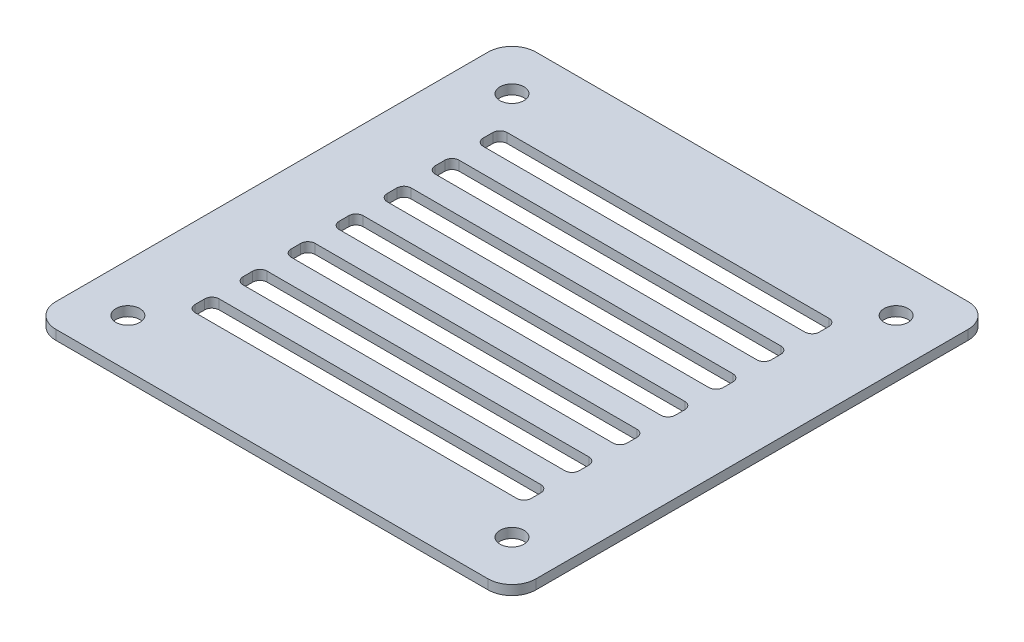
from build123d import *

# Parameters (mm, degrees)
SKETCH1_W           = 100
SKETCH1_H           = 100
SKETCH1_R           = 2.5
SKETCH1_W_2         = 70
SKETCH1_H_2         = 5
BOSS_EXTRUDE1_DEPTH = 2
FILLET1_R           = 5
FILLET2_R           = 1.5


with BuildPart() as part:
    # Sketch1 → Boss-Extrude1 (new body)
    with BuildSketch(Plane(origin=(0, 0, 0), x_dir=(1, 0, 0), z_dir=(0, 1, 0))):
        Rectangle(SKETCH1_W, SKETCH1_H)
        with Locations((-40, 40)):
            Circle(SKETCH1_R, mode=Mode.SUBTRACT)
        with Locations((40, 40)):
            Circle(SKETCH1_R, mode=Mode.SUBTRACT)
        with Locations((40, -40)):
            Circle(SKETCH1_R, mode=Mode.SUBTRACT)
        with Locations((-40, -40)):
            Circle(SKETCH1_R, mode=Mode.SUBTRACT)
        with Locations((0, -30)):
            Rectangle(SKETCH1_W_2, SKETCH1_H_2, mode=Mode.SUBTRACT)
        with Locations((0, -20)):
            Rectangle(SKETCH1_W_2, SKETCH1_H_2, mode=Mode.SUBTRACT)
        with Locations((0, -10)):
            Rectangle(SKETCH1_W_2, SKETCH1_H_2, mode=Mode.SUBTRACT)
        Rectangle(SKETCH1_W_2, SKETCH1_H_2, mode=Mode.SUBTRACT)
        with Locations((0, 10)):
            Rectangle(SKETCH1_W_2, SKETCH1_H_2, mode=Mode.SUBTRACT)
        with Locations((0, 20)):
            Rectangle(SKETCH1_W_2, SKETCH1_H_2, mode=Mode.SUBTRACT)
        with Locations((0, 30)):
            Rectangle(SKETCH1_W_2, SKETCH1_H_2, mode=Mode.SUBTRACT)
    extrude(amount=BOSS_EXTRUDE1_DEPTH)

    # Fillet1
    fillet1_edges = [part.edges().sort_by_distance(p)[0] for p in [
        (50, 1, 50),
        (-50, 1, 50),
        (-50, 1, -50),
        (50, 1, -50),
    ]]
    fillet(fillet1_edges, radius=FILLET1_R)

    # Fillet2
    fillet2_edges = [part.edges().sort_by_distance(p)[0] for p in [
        (35, 1, -27.5),
        (35, 1, -32.5),
        (-35, 1, -32.5),
        (-35, 1, -27.5),
        (35, 1, 32.5),
        (35, 1, 27.5),
        (-35, 1, 27.5),
        (-35, 1, 32.5),
        (35, 1, 22.5),
        (35, 1, 17.5),
        (-35, 1, 17.5),
        (-35, 1, 22.5),
        (35, 1, 12.5),
        (35, 1, 7.5),
        (-35, 1, 7.5),
        (-35, 1, 12.5),
        (35, 1, 2.5),
        (35, 1, -2.5),
        (-35, 1, -2.5),
        (-35, 1, 2.5),
        (35, 1, -7.5),
        (35, 1, -12.5),
        (-35, 1, -12.5),
        (-35, 1, -7.5),
        (35, 1, -17.5),
        (35, 1, -22.5),
        (-35, 1, -22.5),
        (-35, 1, -17.5),
    ]]
    fillet(fillet2_edges, radius=FILLET2_R)


solid = part.part
